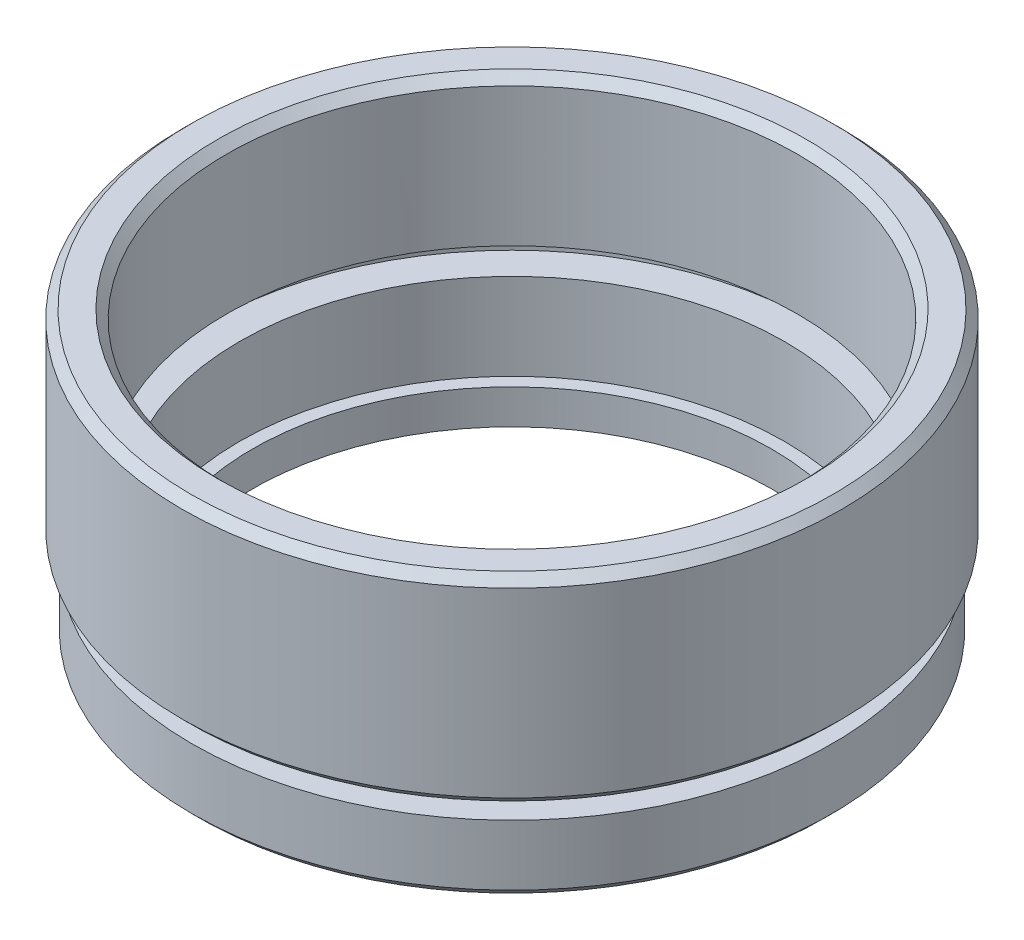
from build123d import *

# Parameters (mm, degrees)
CHAMFER_1_SIZE = 0.5


with BuildPart() as part:
    # 草图1 → 旋转1 (revolve)
    with BuildSketch(Plane.XY, mode=Mode.PRIVATE) as revolve_1_sk:
        Polygon((15, 0), (18.5, 0), (18.5, 4), (17, 4), (17, 5), (19.05, 5), (19.05, 16.5), (16.5, 16.5), (16.5, 8), (17.6, 8), (17.6, 7), (15.75, 7), (15.75, 2), (15, 2), align=None)
    revolve(revolve_1_sk.sketch.rotate(Axis((0, 0, 0), (0, 1, 0)), 90), axis=Axis((0, 0, 0), (0, 1, 0)))  # turned: the seam where the file's is

    # 倒角1
    chamfer_1_edges = [part.edges().sort_by_distance(p)[0] for p in [
        (0, 16.5, 16.5),
        (0, 16.5, 19.05),
        (0, 5, 19.05),
        (0, 0, 18.5),
    ]]
    chamfer(chamfer_1_edges, length=CHAMFER_1_SIZE)


solid = part.part
